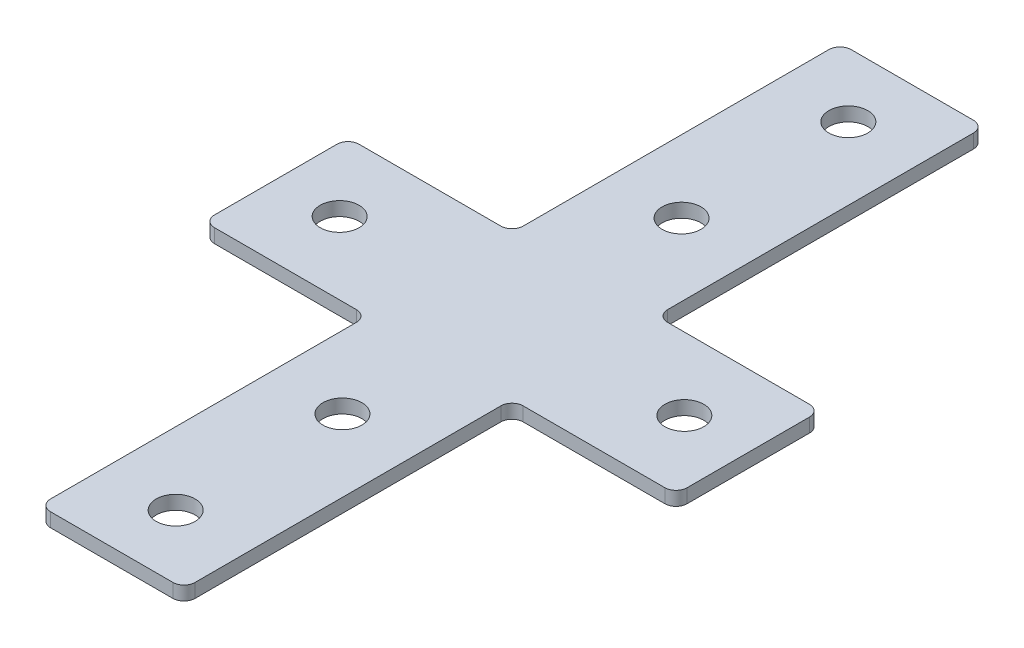
from build123d import *

# Parameters (mm, degrees)
SKETCH_1_R      = 3.5
EXTRUDE_1_DEPTH = 2.5
FILLET_1_R      = 2


with BuildPart() as part:
    # 草图1 → 凸台-拉伸1 (new body)
    with BuildSketch(Plane(origin=(0, 0, 0), x_dir=(1, 0, 0), z_dir=(0, 1, 0))):
        Polygon((-13, 72), (13, 72), (13, 13), (42.5, 13), (42.5, -13), (13, -13), (13, -72), (-13, -72), (-13, -13), (-42.5, -13), (-42.5, 13), (-13, 13), align=None)
        with Locations((0, -60.5)):
            Circle(SKETCH_1_R, mode=Mode.SUBTRACT)
        with Locations((0, -30.5)):
            Circle(SKETCH_1_R, mode=Mode.SUBTRACT)
        with Locations((-31, 0)):
            Circle(SKETCH_1_R, mode=Mode.SUBTRACT)
        with Locations((31, 0)):
            Circle(SKETCH_1_R, mode=Mode.SUBTRACT)
        with Locations((0, 60.5)):
            Circle(SKETCH_1_R, mode=Mode.SUBTRACT)
        with Locations((0, 30.5)):
            Circle(SKETCH_1_R, mode=Mode.SUBTRACT)
    extrude(amount=EXTRUDE_1_DEPTH)

    # 圆角1
    fillet_1_edges = [part.edges().sort_by_distance(p)[0] for p in [
        (13, 1.25, 72),
        (-13, 1.25, 72),
        (-13, 1.25, 13),
        (-42.5, 1.25, 13),
        (-42.5, 1.25, -13),
        (-13, 1.25, -13),
        (-13, 1.25, -72),
        (13, 1.25, -72),
        (13, 1.25, -13),
        (42.5, 1.25, -13),
        (42.5, 1.25, 13),
        (13, 1.25, 13),
    ]]
    fillet(fillet_1_edges, radius=FILLET_1_R)


solid = part.part
